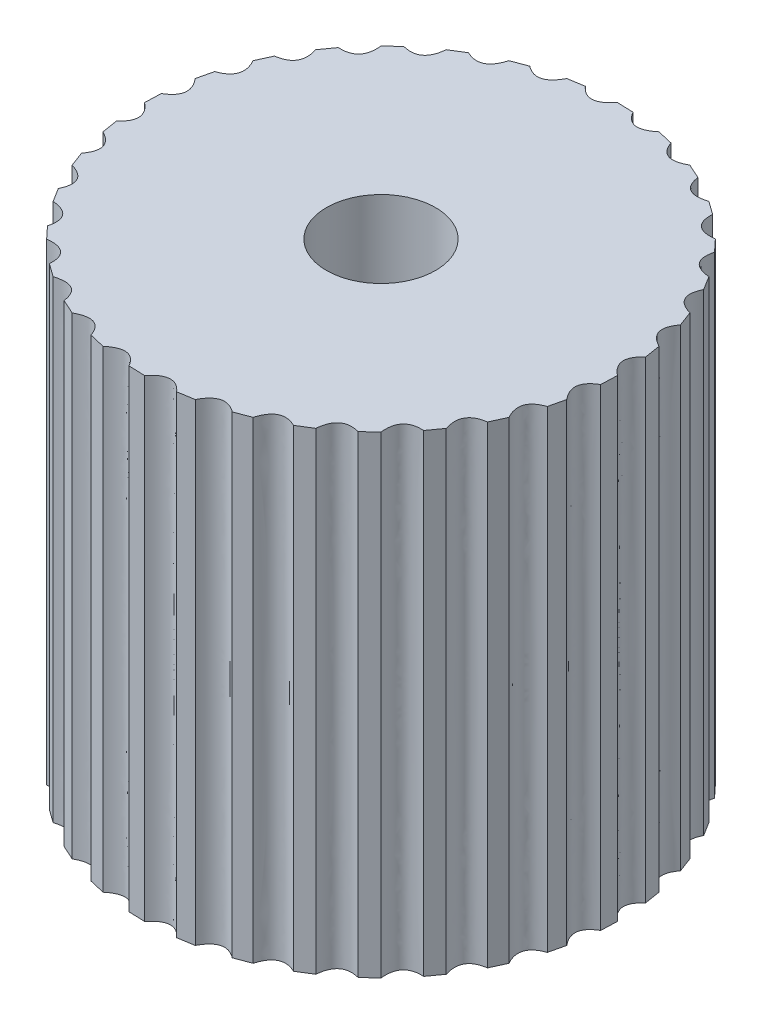
from build123d import *

# Parameters (mm, degrees)
EXTRUDE_1_DEPTH     = 13
SKETCH_2_R          = 1.5
CUT_EXTRUDE_1_DEPTH = 12


with BuildPart() as part:
    # 草图1 → 凸台-拉伸1 (new body)
    with BuildSketch(Plane(origin=(0, 0, 0), x_dir=(1, 0, 0), z_dir=(0, 1, 0))):
        with BuildLine():
            add(Edge.make_bspline(
                [(-6.5, 0), (-5.98419211, -0.416684707), (-6.4469227, -0.828967853)],
                knots=[0, 0, 0, 1, 1, 1], degree=2))
            add(Edge.make_bspline(
                [(-6.4469227, -0.828967853), (-6.375104323, -1.268087093)],
                knots=[0, 0, 1, 1], degree=1))
            add(Edge.make_bspline(
                [(-6.375104323, -1.268087093), (-5.787916383, -1.576136193), (-6.161323283, -2.070771693)],
                knots=[0, 0, 0, 1, 1, 1], degree=2))
            add(Edge.make_bspline(
                [(-6.161323283, -2.070771693), (-6.005216961, -2.48744231)],
                knots=[0, 0, 1, 1], degree=1))
            add(Edge.make_bspline(
                [(-6.005216961, -2.48744231), (-5.369214275, -2.675017649), (-5.638947667, -3.232996939)],
                knots=[0, 0, 0, 1, 1, 1], degree=2))
            add(Edge.make_bspline(
                [(-5.638947667, -3.232996939), (-5.40455248, -3.611206515)],
                knots=[0, 0, 1, 1], degree=1))
            add(Edge.make_bspline(
                [(-5.40455248, -3.611206515), (-4.744176274, -3.671099677), (-4.899870455, -4.270979926)],
                knots=[0, 0, 0, 1, 1, 1], degree=2))
            add(Edge.make_bspline(
                [(-4.899870455, -4.270979926), (-4.596194078, -4.596194078)],
                knots=[0, 0, 1, 1], degree=1))
            add(Edge.make_bspline(
                [(-4.596194078, -4.596194078), (-3.936822239, -4.526103403), (-3.972493969, -5.144831549)],
                knots=[0, 0, 0, 1, 1, 1], degree=2))
            add(Edge.make_bspline(
                [(-3.972493969, -5.144831549), (-3.611206515, -5.40455248)],
                knots=[0, 0, 1, 1], degree=1))
            add(Edge.make_bspline(
                [(-3.611206515, -5.40455248), (-2.978178334, -5.207171513), (-2.892456768, -5.820970181)],
                knots=[0, 0, 0, 1, 1, 1], degree=2))
            add(Edge.make_bspline(
                [(-2.892456768, -5.820970181), (-2.48744231, -6.005216961)],
                knots=[0, 0, 1, 1], degree=1))
            add(Edge.make_bspline(
                [(-2.48744231, -6.005216961), (-1.905084705, -5.688130943), (-1.701264075, -6.273412193)],
                knots=[0, 0, 0, 1, 1, 1], degree=2))
            add(Edge.make_bspline(
                [(-1.701264075, -6.273412193), (-1.268087093, -6.375104323)],
                knots=[0, 0, 1, 1], degree=1))
            add(Edge.make_bspline(
                [(-1.268087093, -6.375104323), (-0.758779739, -5.95049869), (-0.444692758, -6.484770493)],
                knots=[0, 0, 0, 1, 1, 1], degree=2))
            add(Edge.make_bspline(
                [(-0.444692758, -6.484770493), (0, -6.5)],
                knots=[0, 0, 1, 1], degree=1))
            add(Edge.make_bspline(
                [(0, -6.5), (0.416684707, -5.98419211), (0.828967853, -6.4469227)],
                knots=[0, 0, 0, 1, 1, 1], degree=2))
            add(Edge.make_bspline(
                [(0.828967853, -6.4469227), (1.268087093, -6.375104323)],
                knots=[0, 0, 1, 1], degree=1))
            add(Edge.make_bspline(
                [(1.268087093, -6.375104323), (1.576136193, -5.787916383), (2.070771693, -6.161323283)],
                knots=[0, 0, 0, 1, 1, 1], degree=2))
            add(Edge.make_bspline(
                [(2.070771693, -6.161323283), (2.48744231, -6.005216961)],
                knots=[0, 0, 1, 1], degree=1))
            add(Edge.make_bspline(
                [(2.48744231, -6.005216961), (2.675017649, -5.369214275), (3.232996939, -5.638947667)],
                knots=[0, 0, 0, 1, 1, 1], degree=2))
            add(Edge.make_bspline(
                [(3.232996939, -5.638947667), (3.611206515, -5.40455248)],
                knots=[0, 0, 1, 1], degree=1))
            add(Edge.make_bspline(
                [(3.611206515, -5.40455248), (3.671099677, -4.744176274), (4.270979926, -4.899870455)],
                knots=[0, 0, 0, 1, 1, 1], degree=2))
            add(Edge.make_bspline(
                [(4.270979926, -4.899870455), (4.596194078, -4.596194078)],
                knots=[0, 0, 1, 1], degree=1))
            add(Edge.make_bspline(
                [(4.596194078, -4.596194078), (4.526103403, -3.936822239), (5.144831549, -3.972493969)],
                knots=[0, 0, 0, 1, 1, 1], degree=2))
            add(Edge.make_bspline(
                [(5.144831549, -3.972493969), (5.40455248, -3.611206515)],
                knots=[0, 0, 1, 1], degree=1))
            add(Edge.make_bspline(
                [(5.40455248, -3.611206515), (5.207171513, -2.978178334), (5.820970181, -2.892456768)],
                knots=[0, 0, 0, 1, 1, 1], degree=2))
            add(Edge.make_bspline(
                [(5.820970181, -2.892456768), (6.005216961, -2.48744231)],
                knots=[0, 0, 1, 1], degree=1))
            add(Edge.make_bspline(
                [(6.005216961, -2.48744231), (5.688130943, -1.905084705), (6.273412193, -1.701264075)],
                knots=[0, 0, 0, 1, 1, 1], degree=2))
            add(Edge.make_bspline(
                [(6.375104323, -1.268087093), (6.273412193, -1.701264075)],
                knots=[0, 0, 1, 1], degree=1))
            add(Edge.make_bspline(
                [(6.375104323, -1.268087093), (5.95049869, -0.758779739), (6.484770493, -0.444692758)],
                knots=[0, 0, 0, 1, 1, 1], degree=2))
            add(Edge.make_bspline(
                [(6.5, 0), (6.484770493, -0.444692758)],
                knots=[0, 0, 1, 1], degree=1))
            add(Edge.make_bspline(
                [(6.5, 0), (5.98419211, 0.416684707), (6.4469227, 0.828967853)],
                knots=[0, 0, 0, 1, 1, 1], degree=2))
            add(Edge.make_bspline(
                [(6.375104323, 1.268087093), (6.4469227, 0.828967853)],
                knots=[0, 0, 1, 1], degree=1))
            add(Edge.make_bspline(
                [(6.375104323, 1.268087093), (5.787916383, 1.576136193), (6.161323283, 2.070771693)],
                knots=[0, 0, 0, 1, 1, 1], degree=2))
            add(Edge.make_bspline(
                [(6.005216961, 2.48744231), (6.161323283, 2.070771693)],
                knots=[0, 0, 1, 1], degree=1))
            add(Edge.make_bspline(
                [(6.005216961, 2.48744231), (5.369214275, 2.675017649), (5.638947667, 3.232996939)],
                knots=[0, 0, 0, 1, 1, 1], degree=2))
            add(Edge.make_bspline(
                [(5.40455248, 3.611206515), (5.638947667, 3.232996939)],
                knots=[0, 0, 1, 1], degree=1))
            add(Edge.make_bspline(
                [(5.40455248, 3.611206515), (4.744176274, 3.671099677), (4.899870455, 4.270979926)],
                knots=[0, 0, 0, 1, 1, 1], degree=2))
            add(Edge.make_bspline(
                [(4.596194078, 4.596194078), (4.899870455, 4.270979926)],
                knots=[0, 0, 1, 1], degree=1))
            add(Edge.make_bspline(
                [(4.596194078, 4.596194078), (3.936822239, 4.526103403), (3.972493969, 5.144831549)],
                knots=[0, 0, 0, 1, 1, 1], degree=2))
            add(Edge.make_bspline(
                [(3.611206515, 5.40455248), (3.972493969, 5.144831549)],
                knots=[0, 0, 1, 1], degree=1))
            add(Edge.make_bspline(
                [(3.611206515, 5.40455248), (2.978178334, 5.207171513), (2.892456768, 5.820970181)],
                knots=[0, 0, 0, 1, 1, 1], degree=2))
            add(Edge.make_bspline(
                [(2.48744231, 6.005216961), (2.892456768, 5.820970181)],
                knots=[0, 0, 1, 1], degree=1))
            add(Edge.make_bspline(
                [(2.48744231, 6.005216961), (1.905084705, 5.688130943), (1.701264075, 6.273412193)],
                knots=[0, 0, 0, 1, 1, 1], degree=2))
            add(Edge.make_bspline(
                [(1.268087093, 6.375104323), (1.701264075, 6.273412193)],
                knots=[0, 0, 1, 1], degree=1))
            add(Edge.make_bspline(
                [(1.268087093, 6.375104323), (0.758779739, 5.95049869), (0.444692758, 6.484770493)],
                knots=[0, 0, 0, 1, 1, 1], degree=2))
            add(Edge.make_bspline(
                [(0, 6.5), (0.444692758, 6.484770493)],
                knots=[0, 0, 1, 1], degree=1))
            add(Edge.make_bspline(
                [(0, 6.5), (-0.416684707, 5.98419211), (-0.828967853, 6.4469227)],
                knots=[0, 0, 0, 1, 1, 1], degree=2))
            add(Edge.make_bspline(
                [(-1.268087093, 6.375104323), (-0.828967853, 6.4469227)],
                knots=[0, 0, 1, 1], degree=1))
            add(Edge.make_bspline(
                [(-1.268087093, 6.375104323), (-1.576136193, 5.787916383), (-2.070771693, 6.161323283)],
                knots=[0, 0, 0, 1, 1, 1], degree=2))
            add(Edge.make_bspline(
                [(-2.48744231, 6.005216961), (-2.070771693, 6.161323283)],
                knots=[0, 0, 1, 1], degree=1))
            add(Edge.make_bspline(
                [(-2.48744231, 6.005216961), (-2.675017649, 5.369214275), (-3.232996939, 5.638947667)],
                knots=[0, 0, 0, 1, 1, 1], degree=2))
            add(Edge.make_bspline(
                [(-3.611206515, 5.40455248), (-3.232996939, 5.638947667)],
                knots=[0, 0, 1, 1], degree=1))
            add(Edge.make_bspline(
                [(-3.611206515, 5.40455248), (-3.671099677, 4.744176274), (-4.270979926, 4.899870455)],
                knots=[0, 0, 0, 1, 1, 1], degree=2))
            add(Edge.make_bspline(
                [(-4.596194078, 4.596194078), (-4.270979926, 4.899870455)],
                knots=[0, 0, 1, 1], degree=1))
            add(Edge.make_bspline(
                [(-4.596194078, 4.596194078), (-4.526103403, 3.936822239), (-5.144831549, 3.972493969)],
                knots=[0, 0, 0, 1, 1, 1], degree=2))
            add(Edge.make_bspline(
                [(-5.144831549, 3.972493969), (-5.40455248, 3.611206515)],
                knots=[0, 0, 1, 1], degree=1))
            add(Edge.make_bspline(
                [(-5.40455248, 3.611206515), (-5.207171513, 2.978178334), (-5.820970181, 2.892456768)],
                knots=[0, 0, 0, 1, 1, 1], degree=2))
            add(Edge.make_bspline(
                [(-5.820970181, 2.892456768), (-6.005216961, 2.48744231)],
                knots=[0, 0, 1, 1], degree=1))
            add(Edge.make_bspline(
                [(-6.005216961, 2.48744231), (-5.688130943, 1.905084705), (-6.273412193, 1.701264075)],
                knots=[0, 0, 0, 1, 1, 1], degree=2))
            add(Edge.make_bspline(
                [(-6.375104323, 1.268087093), (-6.273412193, 1.701264075)],
                knots=[0, 0, 1, 1], degree=1))
            add(Edge.make_bspline(
                [(-6.375104323, 1.268087093), (-5.95049869, 0.758779739), (-6.484770493, 0.444692758)],
                knots=[0, 0, 0, 1, 1, 1], degree=2))
            add(Edge.make_bspline(
                [(-6.484770493, 0.444692758), (-6.5, 0)],
                knots=[0, 0, 1, 1], degree=1))
        make_face()
    extrude(amount=EXTRUDE_1_DEPTH)

    # 草图2 → 切除-拉伸1 (cut)
    with BuildSketch(Plane(origin=(0, 13, 0), x_dir=(1, 0, 0), z_dir=(0, 1, 0))):
        Circle(SKETCH_2_R)
    extrude(amount=-CUT_EXTRUDE_1_DEPTH, mode=Mode.SUBTRACT)


solid = part.part
